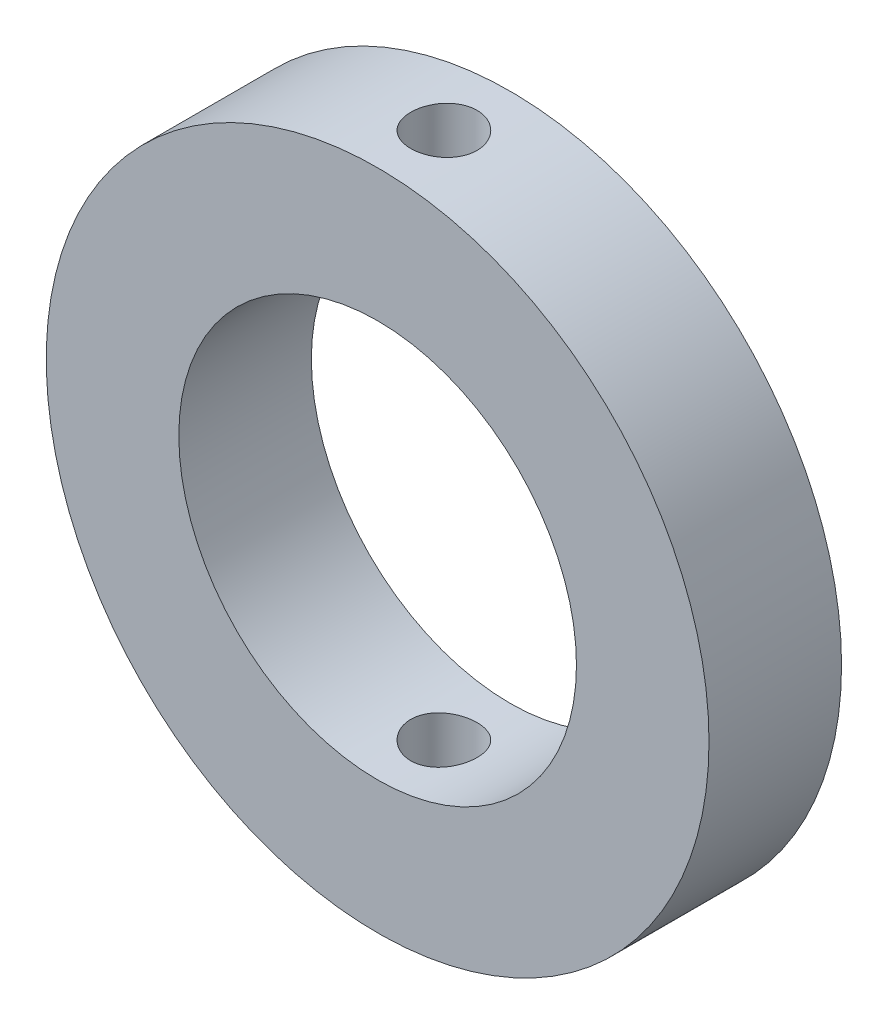
from build123d import *

# Parameters (mm, degrees)
SKETCH1_R           = 25
SKETCH1_R_2         = 15
BOSS_EXTRUDE1_DEPTH = 10
SKETCH2_R           = 2.5
CUT_EXTRUDE1_DEPTH  = 37.5


with BuildPart() as part:
    # Sketch1 → Boss-Extrude1 (new body)
    with BuildSketch(Plane.XY):
        Circle(SKETCH1_R)
        Circle(SKETCH1_R_2, mode=Mode.SUBTRACT)
    extrude(amount=BOSS_EXTRUDE1_DEPTH)

    # Sketch2 → Cut-Extrude1 (cut, symmetric)
    with BuildSketch(Plane(origin=(0, 0, 0), x_dir=(1, 0, 0), z_dir=(0, 1, 0))):
        with Locations((0, -5)):
            Circle(SKETCH2_R)
    extrude(amount=CUT_EXTRUDE1_DEPTH, both=True, mode=Mode.SUBTRACT)


solid = part.part
